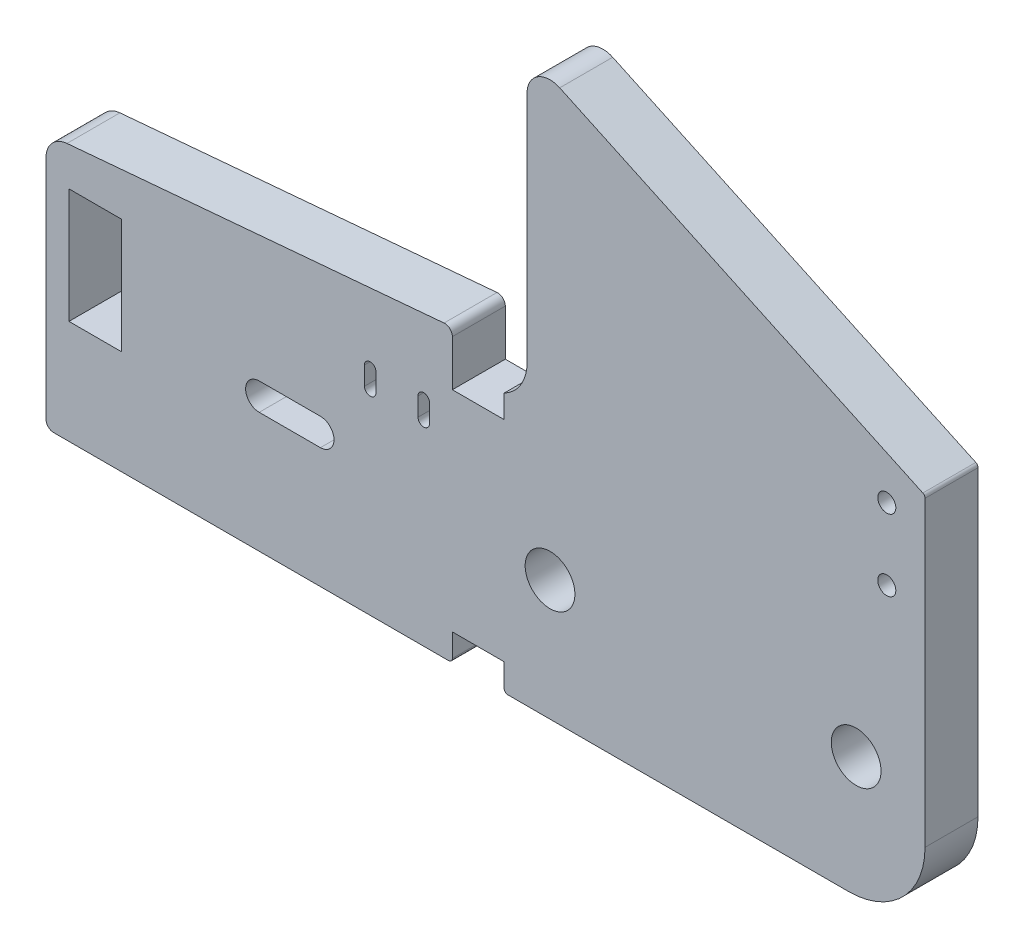
from build123d import *

# Parameters (mm, degrees)
SKETCH1_R           = 3.25
SKETCH1_R_2         = 1.1811
SKETCH1_W           = 6.858
SKETCH1_H           = 15
BOSS_EXTRUDE1_DEPTH = 6.92


with BuildPart() as part:
    # Sketch1 → Boss-Extrude1 (new body)
    with BuildSketch(Plane.XY):
        with BuildLine():
            Line((114.858, 9.999999315), (114.858, 49.5))
            ThreePointArc((114.858, 49.5), (114.779695723, 49.768649804), (114.569309131, 49.953153894))
            Line((114.569309131, 49.953153894), (67.125854783, 72.07639994))
            ThreePointArc((67.125854783, 72.07639994), (64.246101174, 71.887650915), (62.858, 69.357476578))
            Line((62.858, 69.357476578), (62.858, 38.83025734))
            ThreePointArc((62.858, 38.83025734), (62.049059599, 35.944627537), (59.858, 33.9))
            Line((59.858, 33.9), (59.858, 30.9))
            Line((59.858, 30.9), (53.098, 30.9))
            Line((53.098, 30.9), (53.098, 36.908691499))
            ThreePointArc((53.098, 36.908691499), (52.773590208, 37.645968836), (52.010844257, 37.904886197))
            Line((52.010844257, 37.904886197), (2.738532772, 33.594117516))
            ThreePointArc((2.738532772, 33.594117516), (0.78816799, 32.632304045), (0, 30.605533422))
            Line((0, 30.605533422), (0, 1))
            ThreePointArc((0, 1), (0.292893219, 0.292893219), (1, 0))
            Line((1, 0), (52.598, 0))
            ThreePointArc((52.598, 0), (52.951553391, 0.146446609), (53.098, 0.5))
            Line((53.098, 0.5), (53.098, 3.5))
            Line((53.098, 3.5), (59.858, 3.5))
            Line((59.858, 3.5), (59.858, 0.5))
            ThreePointArc((59.858, 0.5), (60.004446609, 0.146446609), (60.358, 0))
            Line((60.358, 0), (104.858, 0))
            ThreePointArc((104.858, 0), (111.92906757, 2.928931946), (114.858, 9.999999315))
        make_face()
        with Locations((65.858, 15.75)):
            Circle(SKETCH1_R, mode=Mode.SUBTRACT)
        with Locations((105.858, 15.75)):
            Circle(SKETCH1_R, mode=Mode.SUBTRACT)
        with Locations((109.858, 37.1528)):
            Circle(SKETCH1_R_2, mode=Mode.SUBTRACT)
        with Locations((109.858, 46.5)):
            Circle(SKETCH1_R_2, mode=Mode.SUBTRACT)
        with BuildLine():
            Line((50.108, 27.95), (50.108, 25.55))
            ThreePointArc((50.108, 25.55), (49.358, 24.8), (48.608, 25.55))
            Line((48.608, 25.55), (48.608, 27.95))
            ThreePointArc((48.608, 27.95), (49.358, 28.7), (50.108, 27.95))
        make_face(mode=Mode.SUBTRACT)
        with BuildLine():
            Line((43.108, 27.95), (43.108, 25.55))
            ThreePointArc((43.108, 25.55), (42.358, 24.8), (41.608, 25.55))
            Line((41.608, 25.55), (41.608, 27.95))
            ThreePointArc((41.608, 27.95), (42.358, 28.7), (43.108, 27.95))
        make_face(mode=Mode.SUBTRACT)
        with BuildLine():
            Line((35.858, 15.725), (27.858, 15.725))
            ThreePointArc((27.858, 15.725), (26.083, 17.5), (27.858, 19.275))
            Line((27.858, 19.275), (35.858, 19.275))
            ThreePointArc((35.858, 19.275), (37.633, 17.5), (35.858, 15.725))
        make_face(mode=Mode.SUBTRACT)
        with Locations((6.429, 21.084021409)):
            Rectangle(SKETCH1_W, SKETCH1_H, mode=Mode.SUBTRACT)
    extrude(amount=BOSS_EXTRUDE1_DEPTH)


solid = part.part
